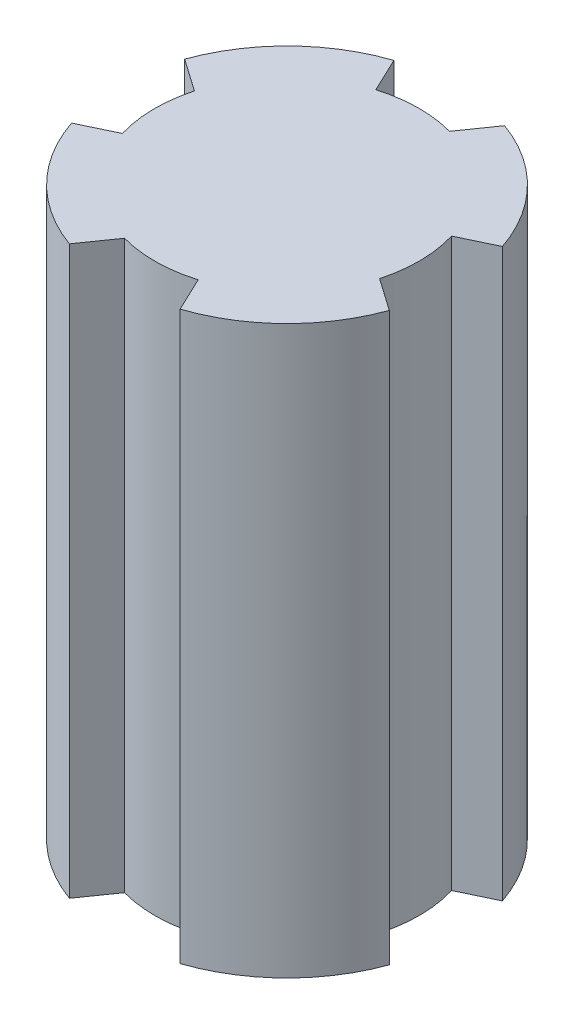
from build123d import *

# Parameters (mm, degrees)
SKETCH1_R           = 4.5
BOSS_EXTRUDE1_DEPTH = 15
CUT_EXTRUDE1_DEPTH  = 15
CIRPATTERN1_COUNT   = 4


with BuildPart() as part:
    # Sketch1 → Boss-Extrude1 (new body)
    with BuildSketch(Plane(origin=(0, 0, 0), x_dir=(1, 0, 0), z_dir=(0, 1, 0))):
        Circle(SKETCH1_R)
    extrude(amount=BOSS_EXTRUDE1_DEPTH)

    # Sketch2 → Cut-Extrude1 (cut)
    with BuildSketch(Plane(origin=(0, 15, 0), x_dir=(1, 0, 0), z_dir=(0, 1, 0))):
        with BuildLine():
            Line((-1.436091353, 4.264697132), (-1.002466053, 3.353365744))
            ThreePointArc((-1.002466053, 3.353365744), (-0.040083536, 3.499770465), (0.925399693, 3.375445957))
            Line((0.925399693, 3.375445957), (1.52547781, 4.233546675))
            ThreePointArc((1.52547781, 4.233546675), (0.047329403, 4.499751096), (-1.436091353, 4.264697132))
        make_face()
    cut_extrude1 = extrude(amount=-CUT_EXTRUDE1_DEPTH, mode=Mode.SUBTRACT)

    # CirPattern1: Cut-Extrude1 ×4 about axis
    cirpattern1_axis = Axis((0, 0, 0), (0, 1, 0))
    for i in range(1, CIRPATTERN1_COUNT):
        add(cut_extrude1.rotate(cirpattern1_axis, i * 360 / CIRPATTERN1_COUNT), mode=Mode.SUBTRACT)


solid = part.part
